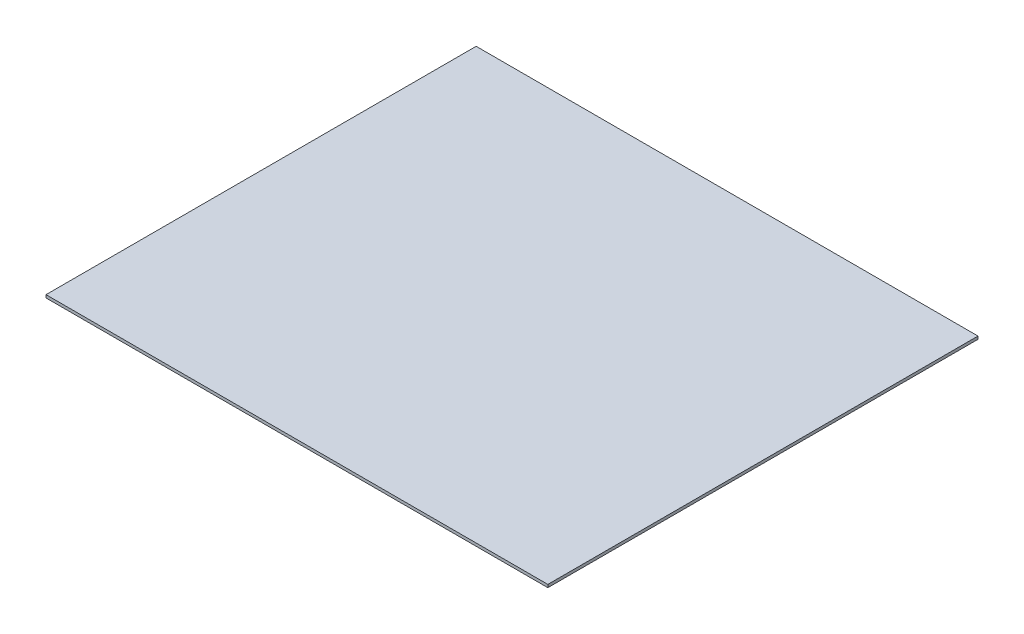
from build123d import *

# Parameters (mm, degrees)
SKETCH1_W           = 700
SKETCH1_H           = 600
BOSS_EXTRUDE1_DEPTH = 4


with BuildPart() as part:
    # Sketch1 → Boss-Extrude1 (new body)
    with BuildSketch(Plane(origin=(0, 0, 0), x_dir=(1, 0, 0), z_dir=(0, 1, 0))):
        with Locations((350, 300)):
            Rectangle(SKETCH1_W, SKETCH1_H)
    extrude(amount=BOSS_EXTRUDE1_DEPTH)


solid = part.part
